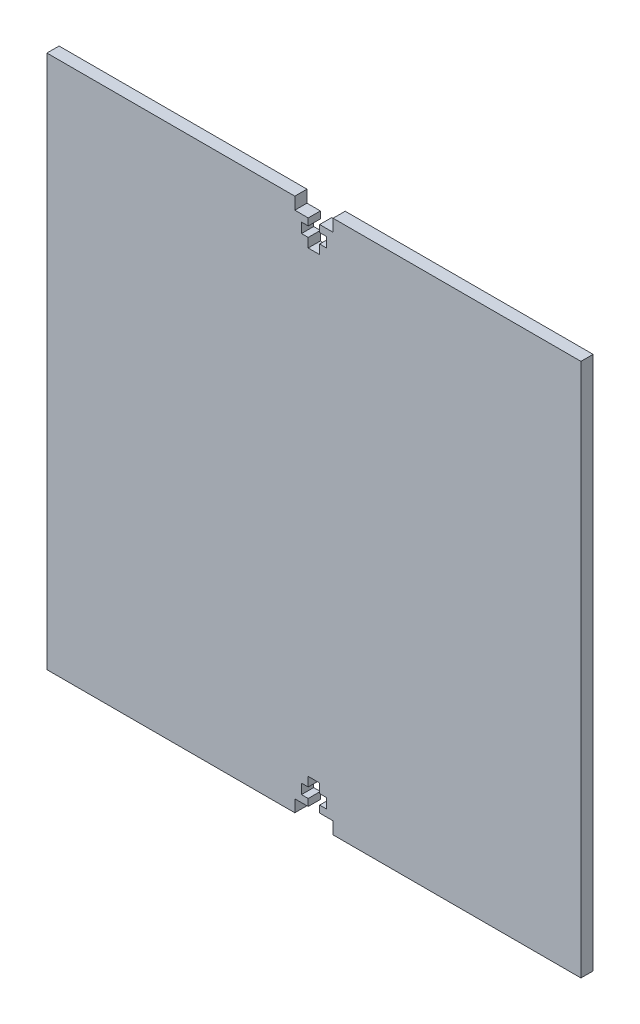
from build123d import *

# Parameters (mm, degrees)
SKETCH1_W           = 139.7
SKETCH1_H           = 139.7
BOSS_EXTRUDE1_DEPTH = 3.18
CUT_EXTRUDE1_DEPTH  = 4.18
CUT_EXTRUDE13_DEPTH = 4.18


with BuildPart() as part:
    # Sketch1 → Boss-Extrude1 (new body)
    with BuildSketch(Plane.XY):
        Rectangle(SKETCH1_W, SKETCH1_H)
    extrude(amount=BOSS_EXTRUDE1_DEPTH)

    # Sketch2 → Cut-Extrude1 (cut, through all)
    with BuildSketch(Plane(origin=(-8.56452252, 11.167189864, 0), x_dir=(-1, 0, 0), z_dir=(0, 0, -1))):
        Polygon((-7.06452252, 55.502810136), (-3.56452252, 55.502810136), (-3.56452252, 58.682810136), (-13.56452252, 58.682810136), (-13.56452252, 55.502810136), (-10.06452252, 55.502810136), (-10.06452252, 53.682810136), (-11.81452252, 53.682810136), (-11.81452252, 51.082810136), (-10.06452252, 51.082810136), (-10.06452252, 48.682810136), (-7.06452252, 48.682810136), (-7.06452252, 51.082810136), (-5.31452252, 51.082810136), (-5.31452252, 53.682810136), (-7.06452252, 53.682810136), align=None)
    extrude(amount=-CUT_EXTRUDE1_DEPTH, mode=Mode.SUBTRACT)

    # Sketch23 → Cut-Extrude13 (cut, through all)
    with BuildSketch(Plane(origin=(17.665263567, -90.063820514, 3.18), x_dir=(1, 0, 0), z_dir=(0, 0, 1))):
        Polygon((-19.165263567, 23.393820514), (-22.665263567, 23.393820514), (-22.665263567, 20.213820514), (-12.665263567, 20.213820514), (-12.665263567, 23.393820514), (-16.165263567, 23.393820514), (-16.165263567, 25.213820514), (-14.415263567, 25.213820514), (-14.415263567, 27.813820514), (-16.165263567, 27.813820514), (-16.165263567, 30.213820514), (-19.165263567, 30.213820514), (-19.165263567, 27.813820514), (-20.915263567, 27.813820514), (-20.915263567, 25.213820514), (-19.165263567, 25.213820514), align=None)
    extrude(amount=-CUT_EXTRUDE13_DEPTH, mode=Mode.SUBTRACT)


solid = part.part
